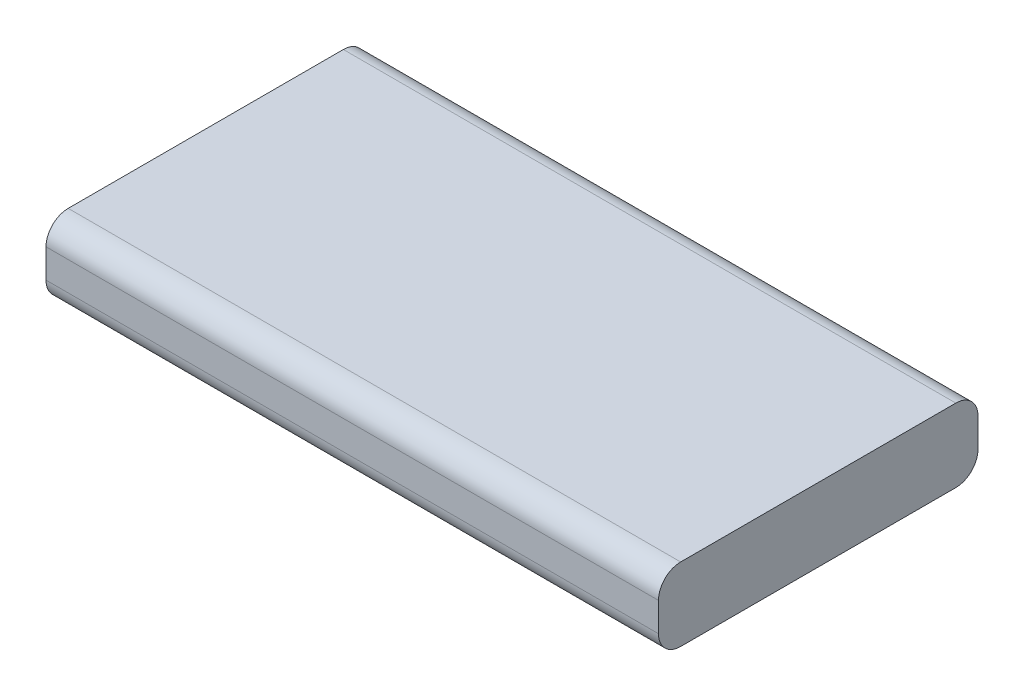
from build123d import *

# Parameters (mm, degrees)
BOSS_EXTRUDE1_DEPTH      = 1.65
BOSS_EXTRUDE1_DEPTH_BACK = 1.65
SKETCH1_W                = 27.6
SKETCH1_H                = 14.4
FILLET1_R                = 1


with BuildPart() as part:
    # Sketch1 → Boss-Extrude1 (new, two sides: drawn at the far end of the back side and taken through both)
    with BuildSketch(Plane(origin=(0, 0, 0), x_dir=(1, 0, 0), z_dir=(0, 1, 0)).offset(-BOSS_EXTRUDE1_DEPTH_BACK)):
        Rectangle(SKETCH1_W, SKETCH1_H)
    extrude(amount=BOSS_EXTRUDE1_DEPTH + BOSS_EXTRUDE1_DEPTH_BACK)

    # Fillet1
    fillet1_edges = [part.edges().sort_by_distance(p)[0] for p in [
        (0, -1.65, -7.2),
        (0, 1.65, -7.2),
        (0, -1.65, 7.2),
        (0, 1.65, 7.2),
    ]]
    fillet(fillet1_edges, radius=FILLET1_R)


solid = part.part
